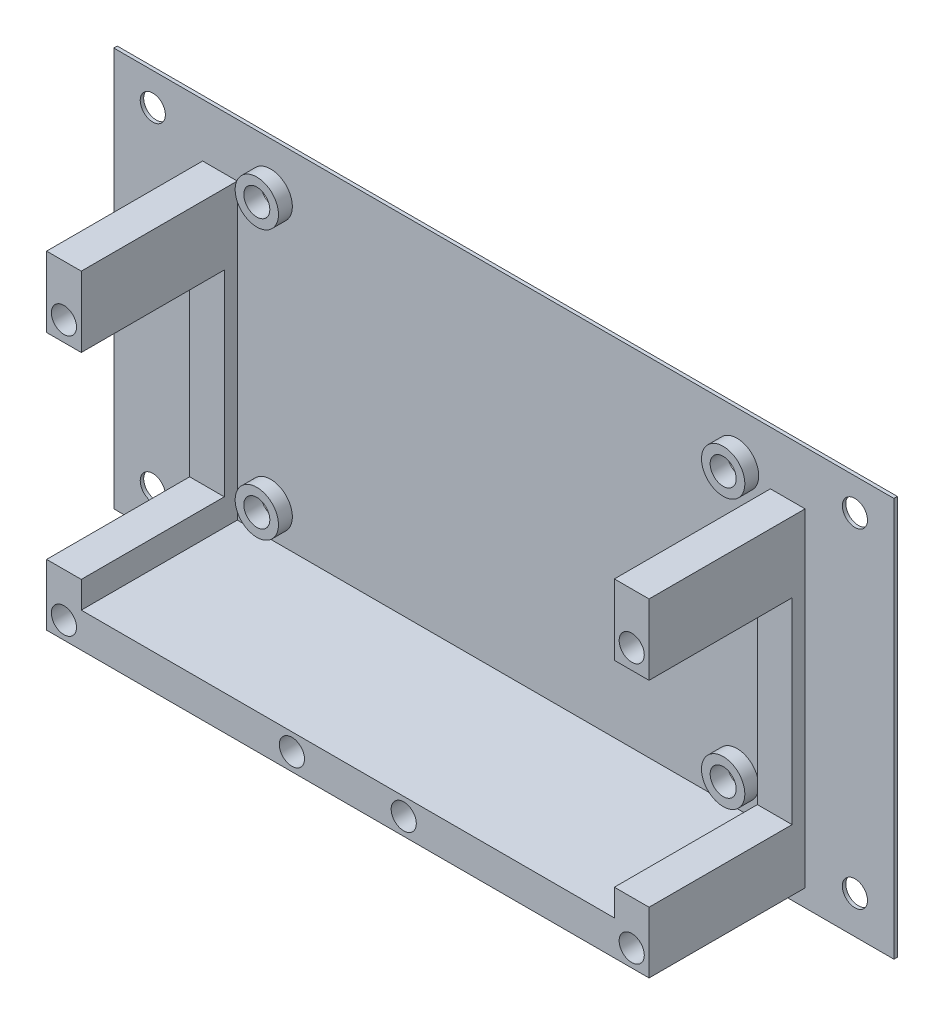
from build123d import *

# Parameters (mm, degrees)
SKIZZE1_W                       = 90
SKIZZE1_H                       = 50
AUFSATZ_LINEAR_AUSTRAGEN1_DEPTH = 0.4
SKIZZE3_R                       = 1.5
SCHNITT_LINEAR_AUSTRAGEN1_DEPTH = 1.4
SKIZZE18_R                      = 2.5
SKIZZE18_R_2                    = 1.5
AUFSATZ_LINEAR_AUSTRAGEN5_DEPTH = 1.6
SKIZZE22_R                      = 1.45
AUFSATZ_LINEAR_AUSTRAGEN7_DEPTH = 18
SKIZZE24_W                      = 4
SKIZZE24_H                      = 22.665276743
AUFSATZ_LINEAR_AUSTRAGEN8_DEPTH = 1.5
SKIZZE25_W                      = 0.4
SKIZZE25_H                      = 3.961895835
SCHNITT_LINEAR_AUSTRAGEN4_DEPTH = 91
SKIZZE26_R                      = 1.45
SCHNITT_LINEAR_AUSTRAGEN5_DEPTH = 1


with BuildPart() as part:
    # Skizze1 → Aufsatz-Linear austragen1 (new body)
    with BuildSketch(Plane.XY):
        Rectangle(SKIZZE1_W, SKIZZE1_H)
    extrude(amount=AUFSATZ_LINEAR_AUSTRAGEN1_DEPTH)

    # Skizze3 → Schnitt-Linear austragen1 (cut, through all)
    with BuildSketch(Plane.XY.offset(0.4)):
        with Locations((-26.9, 19.461895835)):
            Circle(SKIZZE3_R)
        with Locations((26.9, 19.461895835)):
            Circle(SKIZZE3_R)
        with Locations((26.9, -11.538104165)):
            Circle(SKIZZE3_R)
        with Locations((-26.9, -11.538104165)):
            Circle(SKIZZE3_R)
    extrude(amount=-SCHNITT_LINEAR_AUSTRAGEN1_DEPTH, mode=Mode.SUBTRACT)

    # Skizze18 → Aufsatz-Linear austragen5 (add)
    with BuildSketch(Plane.XY.offset(0.4)):
        with Locations((-26.9, 19.461895835)):
            Circle(SKIZZE18_R)
        with Locations((-26.9, 19.461895835)):
            Circle(SKIZZE18_R_2, mode=Mode.SUBTRACT)
        with Locations((26.9, 19.461895835)):
            Circle(SKIZZE18_R)
        with Locations((26.9, 19.461895835)):
            Circle(SKIZZE18_R_2, mode=Mode.SUBTRACT)
        with Locations((26.9, -11.538104165)):
            Circle(SKIZZE18_R)
        with Locations((26.9, -11.538104165)):
            Circle(SKIZZE18_R_2, mode=Mode.SUBTRACT)
        with Locations((-26.9, -11.538104165)):
            Circle(SKIZZE18_R)
        with Locations((-26.9, -11.538104165)):
            Circle(SKIZZE18_R_2, mode=Mode.SUBTRACT)
    extrude(amount=AUFSATZ_LINEAR_AUSTRAGEN5_DEPTH)

    # Skizze22 → Aufsatz-Linear austragen7 (add)
    with BuildSketch(Plane.XY.offset(0.4)):
        Polygon((30.75, -15.038104165), (0, -15.038104165), (-30.75, -15.038104165), (-30.75, -11.965150571), (-34.75, -11.965150571), (-34.75, -19.038104165), (0, -19.038104165), (34.75, -19.038104165), (34.75, -11.965150571), (30.75, -11.965150571), align=None)
        with Locations((32.75, -17.038104165)):
            Circle(SKIZZE22_R, mode=Mode.SUBTRACT)
        with Locations((6.45, -17.038104165)):
            Circle(SKIZZE22_R, mode=Mode.SUBTRACT)
        with Locations((-6.45, -17.038104165)):
            Circle(SKIZZE22_R, mode=Mode.SUBTRACT)
        with Locations((-32.75, -17.038104165)):
            Circle(SKIZZE22_R, mode=Mode.SUBTRACT)
        Polygon((34.75, 15.223665498), (34.75, 18.83332796), (30.75, 18.83332796), (30.75, 15.223665498), (30.75, 10.700126172), (34.75, 10.700126172), align=None)
        with Locations((32.75, 12.961895835)):
            Circle(SKIZZE22_R, mode=Mode.SUBTRACT)
        Polygon((-30.75, 18.83332796), (-30.75, 15.223665498), (-30.75, 10.700126172), (-34.75, 10.700126172), (-34.75, 15.223665498), (-34.75, 18.83332796), align=None)
        with Locations((-32.75, 12.961895835)):
            Circle(SKIZZE22_R, mode=Mode.SUBTRACT)
    extrude(amount=AUFSATZ_LINEAR_AUSTRAGEN7_DEPTH)

    # Skizze24 → Aufsatz-Linear austragen8 (add)
    with BuildSketch(Plane.XY.offset(0.4)):
        with Locations((-32.75, -0.632512199)):
            Rectangle(SKIZZE24_W, SKIZZE24_H)
        with Locations((32.75, -0.632512199)):
            Rectangle(SKIZZE24_W, SKIZZE24_H)
    extrude(amount=AUFSATZ_LINEAR_AUSTRAGEN8_DEPTH)

    # Skizze25 → Schnitt-Linear austragen4 (cut, through all)
    with BuildSketch(Plane(origin=(45, 0, 0), x_dir=(0, 0, -1), z_dir=(1, 0, 0))):
        with Locations((-0.2, -23.019052083)):
            Rectangle(SKIZZE25_W, SKIZZE25_H)
    extrude(amount=-SCHNITT_LINEAR_AUSTRAGEN4_DEPTH, mode=Mode.SUBTRACT)

    # Skizze26 → Schnitt-Linear austragen5 (cut)
    with BuildSketch(Plane(origin=(0, 0, 0), x_dir=(-1, 0, 0), z_dir=(0, 0, -1))):
        with Locations((-40.5, -16.7)):
            Circle(SKIZZE26_R)
        with Locations((-40.5, 21.3)):
            Circle(SKIZZE26_R)
        with Locations((40.5, -16.7)):
            Circle(SKIZZE26_R)
        with Locations((40.5, 21.3)):
            Circle(SKIZZE26_R)
    extrude(amount=-SCHNITT_LINEAR_AUSTRAGEN5_DEPTH, mode=Mode.SUBTRACT)


solid = part.part
